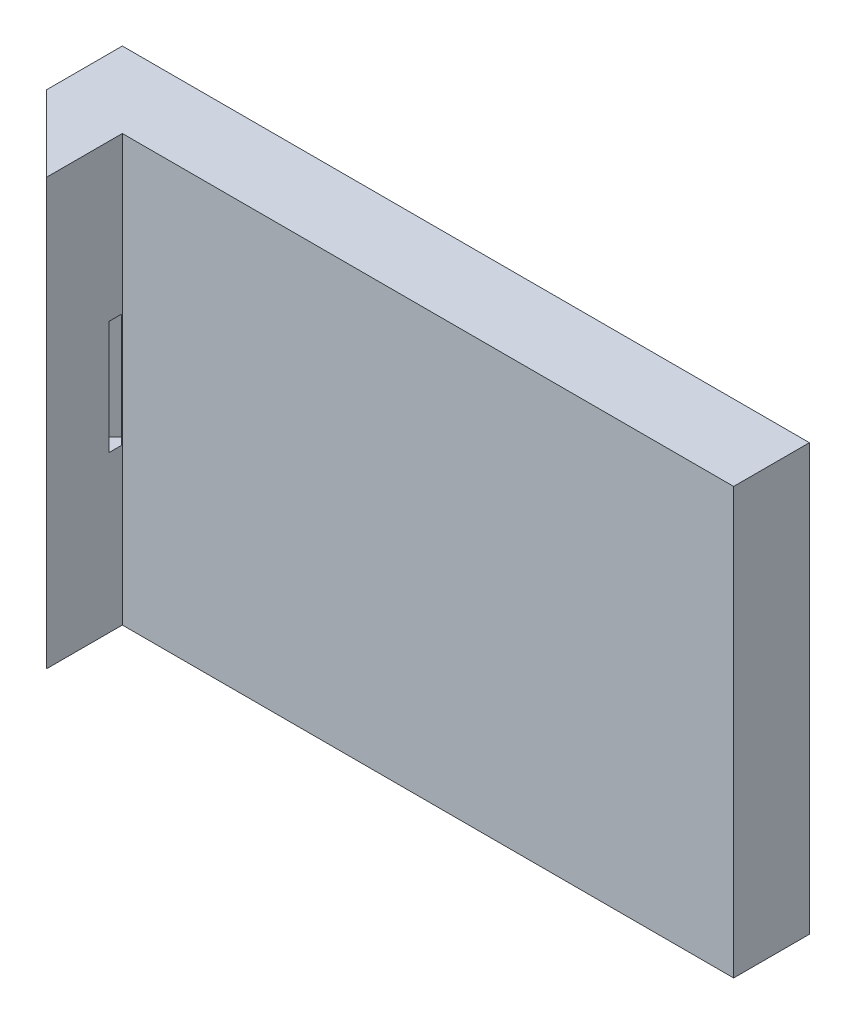
from build123d import *

# Parameters (mm, degrees)
SKETCH1_W           = 350
SKETCH1_H           = 56.2
BOSS_EXTRUDE1_DEPTH = 10
SKETCH2_W           = 56.2
SKETCH2_H           = 56.2
CUT_EXTRUDE1_DEPTH  = 5
SKETCH3_W           = 10
SKETCH3_H           = 56.2
BOSS_EXTRUDE2_DEPTH = 10
SKETCH4_W           = 10
SKETCH4_H           = 56.2
BOSS_EXTRUDE3_DEPTH = 10
CUT_EXTRUDE2_DEPTH  = 56.2
SKETCH6_W           = 10
SKETCH6_H           = 56.2
BOSS_EXTRUDE4_DEPTH = 10
SKETCH7_W           = 10
SKETCH7_H           = 56.2
BOSS_EXTRUDE5_DEPTH = 10
CUT_EXTRUDE3_DEPTH  = 56.2
SKETCH9_W           = 30
SKETCH9_H           = 30
CUT_EXTRUDE4_DEPTH  = 5
SKETCH10_R          = 3
CUT_EXTRUDE5_DEPTH  = 5
SKETCH11_W          = 2.5
SKETCH11_H          = 15
CUT_EXTRUDE6_DEPTH  = 7
SKETCH12_W          = 2.5
SKETCH12_H          = 15
CUT_EXTRUDE7_DEPTH  = 7
SKETCH14_W          = 279.3
SKETCH14_H          = 56.2
CUT_EXTRUDE10_DEPTH = 10


with BuildPart() as part:
    # Sketch1 → Boss-Extrude1 (new body)
    with BuildSketch(Plane.XY):
        Rectangle(SKETCH1_W, SKETCH1_H)
    extrude(amount=BOSS_EXTRUDE1_DEPTH)

    # Sketch2 → Cut-Extrude1 (cut)
    with BuildSketch(Plane.XY.offset(10)):
        Rectangle(SKETCH2_W, SKETCH2_H)
    extrude(amount=-CUT_EXTRUDE1_DEPTH, mode=Mode.SUBTRACT)

    # Sketch3 → Boss-Extrude2 (add)
    with BuildSketch(Plane(origin=(175, 0, 0), x_dir=(0, 0, -1), z_dir=(1, 0, 0))):
        with Locations((-5, 0)):
            Rectangle(SKETCH3_W, SKETCH3_H)
    extrude(amount=BOSS_EXTRUDE2_DEPTH)

    # Sketch4 → Boss-Extrude3 (add)
    with BuildSketch(Plane.XY.offset(10)):
        with Locations((180, 0)):
            Rectangle(SKETCH4_W, SKETCH4_H)
    extrude(amount=BOSS_EXTRUDE3_DEPTH)

    # Sketch5 → Cut-Extrude2 (cut)
    with BuildSketch(Plane(origin=(0, 28.1, 0), x_dir=(1, 0, 0), z_dir=(0, 1, 0))):
        Polygon((175, -20), (185, -10), (185, -20), align=None)
    extrude(amount=-CUT_EXTRUDE2_DEPTH, mode=Mode.SUBTRACT)

    # Sketch6 → Boss-Extrude4 (add)
    with BuildSketch(Plane.ZY.offset(175)):
        with Locations((5, 0)):
            Rectangle(SKETCH6_W, SKETCH6_H)
    extrude(amount=BOSS_EXTRUDE4_DEPTH)

    # Sketch7 → Boss-Extrude5 (add)
    with BuildSketch(Plane.XY.offset(10)):
        with Locations((-180, 0)):
            Rectangle(SKETCH7_W, SKETCH7_H)
    extrude(amount=BOSS_EXTRUDE5_DEPTH)

    # Sketch8 → Cut-Extrude3 (cut)
    with BuildSketch(Plane(origin=(0, 28.1, 0), x_dir=(1, 0, 0), z_dir=(0, 1, 0))):
        Polygon((-175, -20), (-185, -10), (-185, -20), align=None)
    extrude(amount=-CUT_EXTRUDE3_DEPTH, mode=Mode.SUBTRACT)

    # Sketch9 → Cut-Extrude4 (cut)
    with BuildSketch(Plane.XY.offset(5)):
        Rectangle(SKETCH9_W, SKETCH9_H)
    extrude(amount=-CUT_EXTRUDE4_DEPTH, mode=Mode.SUBTRACT)

    # Sketch10 → Cut-Extrude5 (cut)
    with BuildSketch(Plane.XY.offset(5)):
        with Locations((21.55, 21.55)):
            Circle(SKETCH10_R)
        with Locations((-21.55, -21.55)):
            Circle(SKETCH10_R)
        with Locations((-21.55, 21.55)):
            Circle(SKETCH10_R)
        with Locations((21.55, -21.55)):
            Circle(SKETCH10_R)
    extrude(amount=-CUT_EXTRUDE5_DEPTH, mode=Mode.SUBTRACT)

    # Sketch11 → Cut-Extrude6 (cut)
    with BuildSketch(Plane(origin=(97.5, 0, 97.5), x_dir=(0.7071067811865478, 0, -0.7071067811865472), z_dir=(0.7071067811865472, 0, 0.7071067811865478))):
        with Locations((116.672618896, 0)):
            Rectangle(SKETCH11_W, SKETCH11_H)
    extrude(amount=-CUT_EXTRUDE6_DEPTH, mode=Mode.SUBTRACT)

    # Sketch12 → Cut-Extrude7 (cut)
    with BuildSketch(Plane(origin=(-97.5, 0, 97.5), x_dir=(0.7071067811865478, 0, 0.7071067811865472), z_dir=(-0.7071067811865472, 0, 0.7071067811865478))):
        with Locations((-116.672618896, 0)):
            Rectangle(SKETCH12_W, SKETCH12_H)
    extrude(amount=-CUT_EXTRUDE7_DEPTH, mode=Mode.SUBTRACT)

    # Sketch14 → Cut-Extrude10 (cut)
    with BuildSketch(Plane.XY.offset(10)):
        with Locations((45.35, 0)):
            Rectangle(SKETCH14_W, SKETCH14_H)
    extrude(amount=-CUT_EXTRUDE10_DEPTH, mode=Mode.SUBTRACT)


with BuildPart() as body_2:
    # of the pieces the cut leaves, the one that is kept (cut_extrude10_keep)
    add(part.part.solids().sort_by_distance((-185, -28.1, 0))[0])


solid = body_2.part
